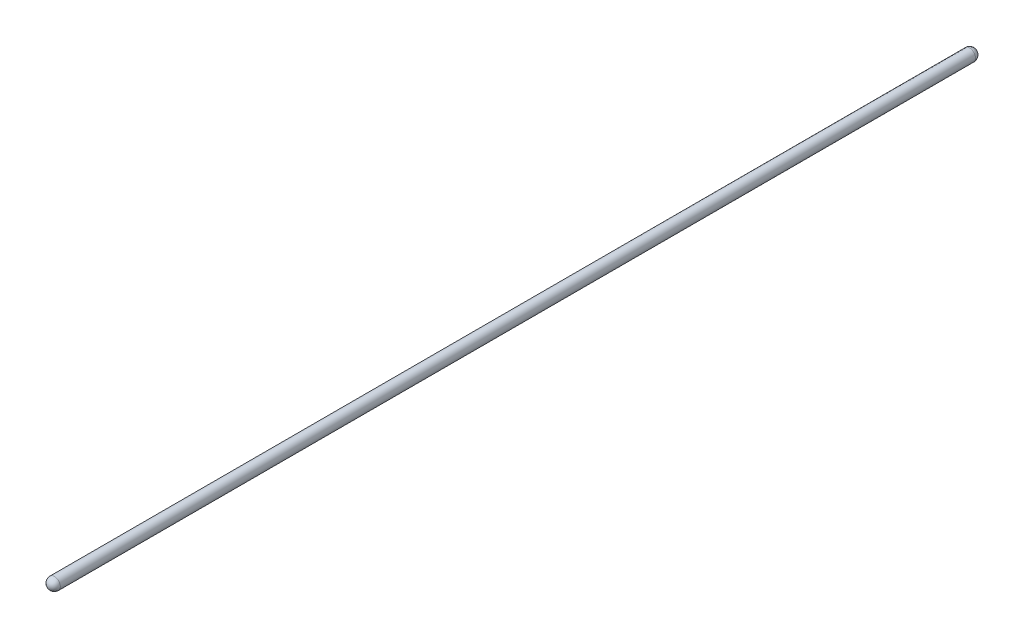
from build123d import *


with BuildPart() as part:
    # Sketch1 → Revolve1 (revolve)
    with BuildSketch(Plane(origin=(0, 0, 0), x_dir=(1, 0, 0), z_dir=(0, 1, 0))):
        with BuildLine():
            Line((9.525, 0), (9.525, -1466.85))
            ThreePointArc((9.525, -1466.85), (6.735192091, -1473.585192091), (0, -1476.375))
            Line((0, -1476.375), (0, 9.525))
            ThreePointArc((0, 9.525), (6.735192091, 6.735192091), (9.525, 0))
        make_face()
    revolve(axis=Axis((0, 0, -9.525), (0, 0, 1)))


solid = part.part
